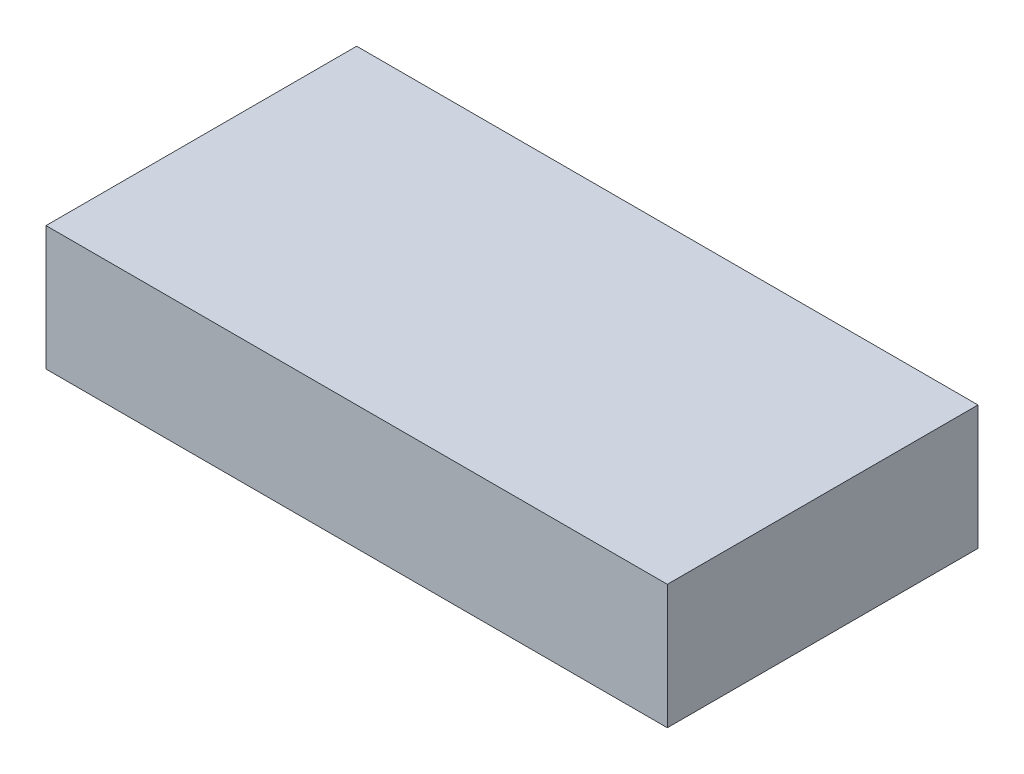
from build123d import *

# Parameters (mm, degrees)
SKETCH1_W           = 10
SKETCH1_H           = 5
BOSS_EXTRUDE1_DEPTH = 2


with BuildPart() as part:
    # Sketch1 → Boss-Extrude1 (new body)
    with BuildSketch(Plane(origin=(0, 0, 0), x_dir=(1, 0, 0), z_dir=(0, 1, 0))):
        with Locations((5, 2.5)):
            Rectangle(SKETCH1_W, SKETCH1_H)
    extrude(amount=BOSS_EXTRUDE1_DEPTH)


solid = part.part
